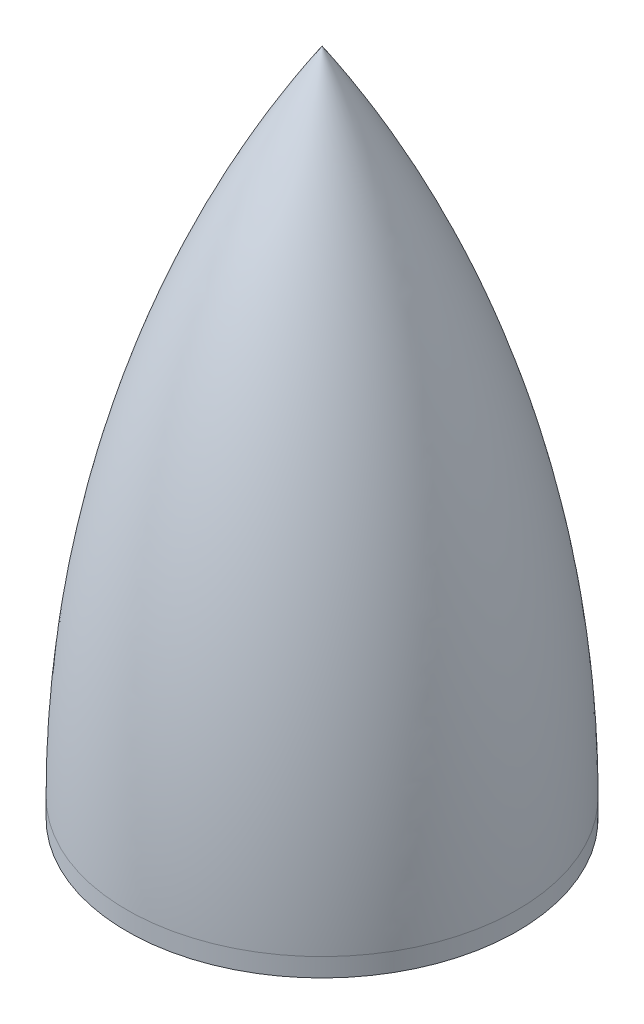
from build123d import *

# Parameters (mm, degrees)
REVOLVE1_ANGLE = 360


with BuildPart() as part:
    # Sketch1 → Revolve1 (revolve, symmetric)
    with BuildSketch(Plane.XY) as revolve1_sk:
        with BuildLine():
            Line((-1.5875, 0), (-22.225, 0))
            Line((-22.225, 0), (-22.225, 2.1082))
            ThreePointArc((-22.225, 2.1082), (-16.549088511, 40.784890177), (0, 76.2))
            Line((0, 76.2), (0, 73.845140026))
            ThreePointArc((0, 73.845140026), (-15.674539498, 39.477580428), (-21.1836, 2.1082))
            Line((-21.1836, 2.1082), (-6.35, 2.1082))
            Line((-6.35, 2.1082), (-6.35, 6.35))
            Line((-6.35, 6.35), (-1.5875, 6.35))
            Line((-1.5875, 6.35), (-1.5875, 2.1082))
            Line((-1.5875, 2.1082), (-1.5875, 0))
        make_face()
    revolve(axis=Axis((0, 0, 0), (0, 1, 0)), revolution_arc=REVOLVE1_ANGLE / 2)
    revolve(revolve1_sk.sketch, axis=Axis((0, 0, 0), (0, -1, 0)), revolution_arc=REVOLVE1_ANGLE / 2)


solid = part.part
